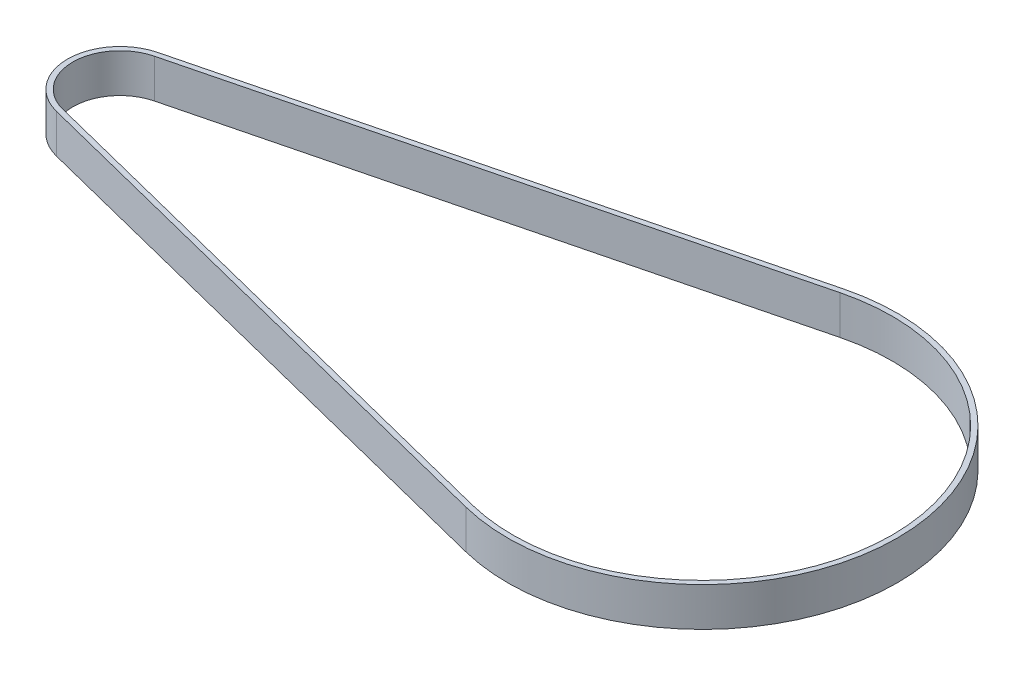
from build123d import *

# Parameters (mm, degrees)
BOSS_EXTRUDE1_DEPTH = 6


with BuildPart() as part:
    # Sketch1 → Boss-Extrude1 (new body)
    with BuildSketch(Plane(origin=(0, 0, 0), x_dir=(1, 0, 0), z_dir=(0, 1, 0))):
        with BuildLine():
            Line((-91.98, 7.854272723), (-7.357777778, 29.186865302))
            ThreePointArc((-7.357777778, 29.186865302), (30.1, 0), (-7.357777778, -29.186865302))
            Line((-7.357777778, -29.186865302), (-91.98, -7.854272723))
            ThreePointArc((-91.98, -7.854272723), (-98.1, 0), (-91.98, 7.854272723))
        make_face()
        with BuildLine():
            Line((-91.784444444, 7.078542083), (-7.162222222, 28.411134663))
            ThreePointArc((-7.162222222, 28.411134663), (29.3, 0), (-7.162222222, -28.411134663))
            Line((-7.162222222, -28.411134663), (-91.784444444, -7.078542083))
            ThreePointArc((-91.784444444, -7.078542083), (-97.3, 0), (-91.784444444, 7.078542083))
        make_face(mode=Mode.SUBTRACT)
    extrude(amount=BOSS_EXTRUDE1_DEPTH)


solid = part.part
